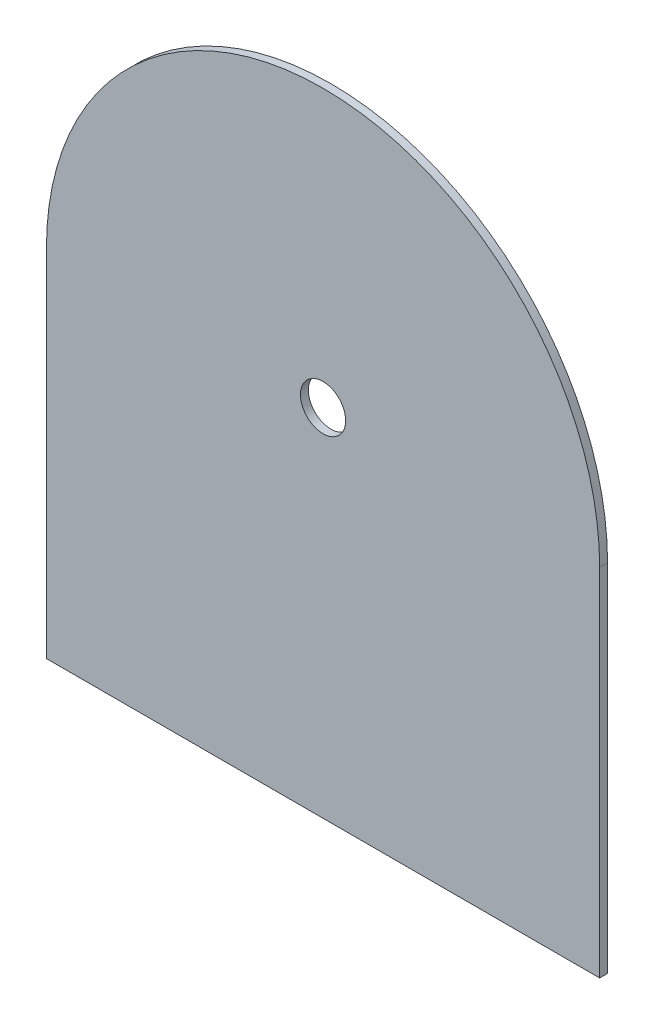
from build123d import *

# Parameters (mm, degrees)
OUTER_CASING_DEPTH = 5
SKETCH1_R          = 14.3
INNER_CUTOUT_DEPTH = 10


with BuildPart() as part:
    # Plate shape → Outer casing (new body)
    with BuildSketch(Plane.XY):
        with BuildLine():
            Line((-175, 225), (-175, 0))
            Line((-175, 0), (175, 0))
            Line((175, 0), (175, 225))
            ThreePointArc((175, 225), (0, 400), (-175, 225))
        make_face()
    extrude(amount=OUTER_CASING_DEPTH)

    # Sketch1 → Inner Cutout (cut)
    with BuildSketch(Plane.XY.offset(5)):
        with Locations((0, 225)):
            Circle(SKETCH1_R)
    extrude(amount=-INNER_CUTOUT_DEPTH, mode=Mode.SUBTRACT)


solid = part.part
